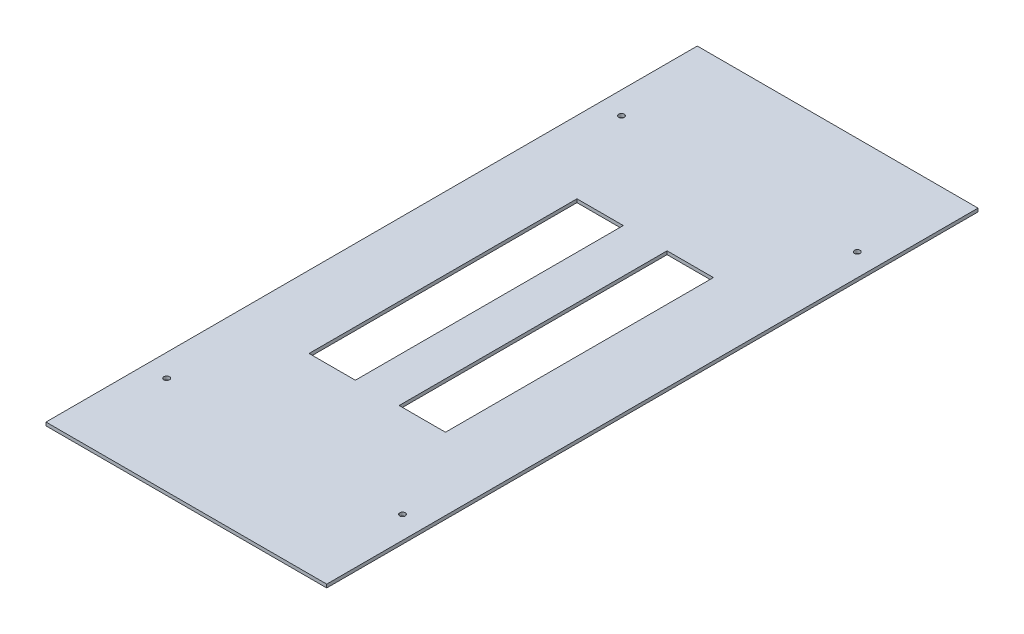
from build123d import *

# Parameters (mm, degrees)
SKETCH1_W                = 230
SKETCH1_H                = 425
BOSS_EXTRUDE1_DEPTH      = 3
F_5_0_4_DIAMETER_HOLE1_D = 5
SKETCH5_W                = 41.25
SKETCH5_H                = 238.6
CUT_EXTRUDE1_DEPTH       = 4
SKETCH6_W                = 250
SKETCH6_H                = 580
SKETCH6_W_2              = 230
SKETCH6_H_2              = 425
BOSS_EXTRUDE3_DEPTH      = 3


with BuildPart() as part:
    # Sketch1 → Boss-Extrude1 (new body)
    with BuildSketch(Plane(origin=(0, 0, 0), x_dir=(1, 0, 0), z_dir=(0, 1, 0))):
        Rectangle(SKETCH1_W, SKETCH1_H)
    extrude(amount=-BOSS_EXTRUDE1_DEPTH)

    # Ø5.0 (4) Diameter Hole1 (through all)
    with Locations(Plane(origin=(0, 0, 0), x_dir=(1, 0, 0), z_dir=(0, 1, 0))):
        with Locations((-105, 202.5), (105, 202.5), (105, -202.5), (-105, -202.5)):
            Hole(F_5_0_4_DIAMETER_HOLE1_D / 2)

    # Sketch5 → Cut-Extrude1 (cut, through all)
    with BuildSketch(Plane(origin=(0, 0, 0), x_dir=(1, 0, 0), z_dir=(0, 1, 0))):
        with Locations((-40.125, -0.7)):
            Rectangle(SKETCH5_W, SKETCH5_H)
        with Locations((40.125, -0.7)):
            Rectangle(SKETCH5_W, SKETCH5_H)
    extrude(amount=-CUT_EXTRUDE1_DEPTH, mode=Mode.SUBTRACT)

    # Sketch6 → Boss-Extrude3 (add)
    with BuildSketch(Plane(origin=(0, 0, 0), x_dir=(1, 0, 0), z_dir=(0, 1, 0))):
        Rectangle(SKETCH6_W, SKETCH6_H)
        Rectangle(SKETCH6_W_2, SKETCH6_H_2, mode=Mode.SUBTRACT)
    extrude(amount=-BOSS_EXTRUDE3_DEPTH)


solid = part.part
